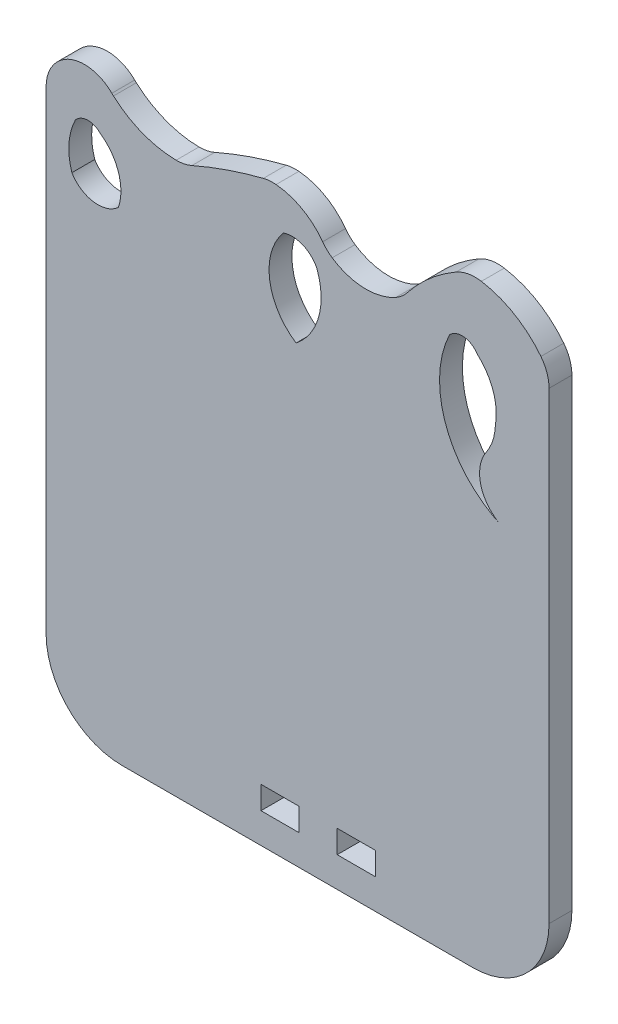
from build123d import *

# Parameters (mm, degrees)
MODEL_W                 = 5
MODEL_H                 = 3
SALIENTE_EXTRUIR1_DEPTH = 3


with BuildPart() as part:
    # Model → Saliente-Extruir1 (new body)
    with BuildSketch(Plane.XY):
        with BuildLine():
            ThreePointArc((41.267867754, 50.3668743), (41.840038745, 49.712625685), (42.516862734, 49.167345775))
            ThreePointArc((42.516862734, 49.167345775), (46.658942321, 47.821013343), (50.890017113, 48.854183425))
            ThreePointArc((50.890017113, 48.854183425), (51.682739903, 49.412356399), (52.352838083, 50.113023882))
            ThreePointArc((52.352838083, 50.113023882), (55.298688256, 53.204742994), (58.776644321, 55.682762754))
            ThreePointArc((58.776644321, 55.682762754), (60.384709339, 56.272809284), (62.097562925, 56.285482302))
            ThreePointArc((62.097562925, 56.285482302), (66.436098934, 54.702702392), (69.908221839, 51.657632693))
            ThreePointArc((69.908221839, 51.657632693), (70.701503033, 50.2031837), (70.975974725, 48.569359286))
            Line((70.975974725, 48.569359286), (70.975974725, -12.270034891))
            ThreePointArc((70.975974725, -12.270034891), (68.051211593, -19.336931187), (60.987770072, -22.270027934))
            Line((60.987770072, -22.270027934), (14.985714259, -22.315810799))
            ThreePointArc((14.985714259, -22.315810799), (7.908350506, -19.39032634), (4.975973655, -12.315815543))
            Line((4.975973655, -12.315815543), (4.975973655, -2.813238517))
            Line((4.975973655, -2.813238517), (4.975973655, 40.425288245))
            Line((4.975973655, 40.425288245), (4.975973655, 49.884528276))
            ThreePointArc((4.975973655, 49.884528276), (8.113744062, 54.521049823), (13.601344724, 53.412368555))
            ThreePointArc((13.601344724, 53.412368555), (13.707091478, 53.309379729), (13.815832279, 53.209557326))
            ThreePointArc((13.815832279, 53.209557326), (17.640590842, 50.871877459), (22.042476183, 50.025159874))
            ThreePointArc((22.042476183, 50.025159874), (23.098925942, 50.126451448), (24.110198526, 50.448435664))
            ThreePointArc((24.110198526, 50.448435664), (28.729757377, 52.257521246), (33.482882411, 53.679110861))
            ThreePointArc((33.482882411, 53.679110861), (34.313026149, 53.81737559), (35.154600394, 53.814451111))
            ThreePointArc((35.154600394, 53.814451111), (38.583837662, 52.751366), (41.267867754, 50.3668743))
        make_face()
        with Locations((45.675973655, -16.835371011)):
            Rectangle(MODEL_W, MODEL_H, mode=Mode.SUBTRACT)
        with Locations((35.675973655, -16.835371011)):
            Rectangle(MODEL_W, MODEL_H, mode=Mode.SUBTRACT)
        with BuildLine():
            ThreePointArc((61.544611159, 47.747091698), (59.825660646, 48.823765634), (57.918666613, 48.13283048))
            ThreePointArc((57.918666613, 48.13283048), (57.495803013, 37.456958674), (64.907336248, 29.761360741))
            ThreePointArc((64.907336248, 29.761360741), (62.061503492, 32.95773428), (62.730808451, 37.184742531))
            ThreePointArc((62.730808451, 37.184742531), (63.597745225, 38.946667832), (63.936191604, 40.880941387))
            ThreePointArc((63.936191604, 40.880941387), (63.639107759, 44.627049101), (61.544611159, 47.747091698))
        make_face(mode=Mode.SUBTRACT)
        with BuildLine():
            ThreePointArc((37.783690328, 37.119649339), (40.764172897, 41.613475795), (40.490547933, 46.998908176))
            ThreePointArc((40.490547933, 46.998908176), (38.645359064, 48.710978233), (36.129518354, 48.791298643))
            ThreePointArc((36.129518354, 48.791298643), (34.308280563, 42.580138607), (37.783690328, 37.119649339))
        make_face(mode=Mode.SUBTRACT)
        with BuildLine():
            ThreePointArc((8.359011818, 41.762359599), (11.200768363, 39.871762064), (14.466790556, 40.863244963))
            ThreePointArc((14.466790556, 40.863244963), (14.466640554, 44.89370885), (12.048482223, 48.118169962))
            ThreePointArc((12.048482223, 48.118169962), (10.408906396, 48.767789115), (8.824071113, 47.99415415))
            ThreePointArc((8.824071113, 47.99415415), (7.978922821, 44.923974684), (8.359011818, 41.762359599))
        make_face(mode=Mode.SUBTRACT)
    extrude(amount=SALIENTE_EXTRUIR1_DEPTH)


solid = part.part
